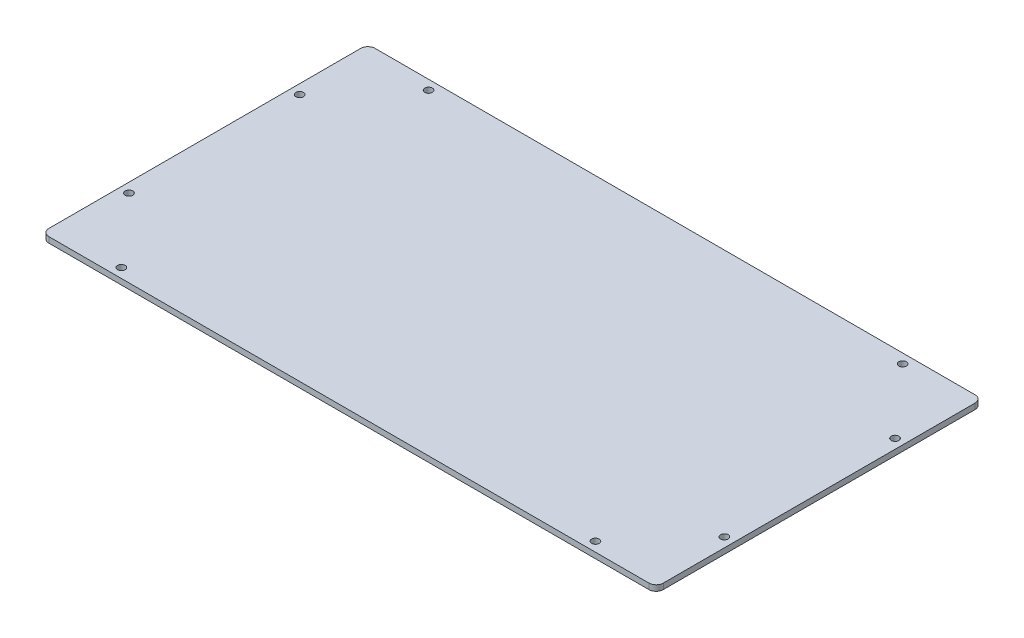
from build123d import *

# Parameters (mm, degrees)
SKETCH_1_R      = 2
EXTRUDE_1_DEPTH = 3


with BuildPart() as part:
    # 草图1 → 凸台-拉伸1 (new body)
    with BuildSketch(Plane.XZ.offset(3)):
        with BuildLine():
            Line((162, -82.2), (162, 82.2))
            ThreePointArc((162, 82.2), (160.887005769, 84.887005769), (158.2, 86))
            Line((158.2, 86), (-158.2, 86))
            ThreePointArc((-158.2, 86), (-160.887005769, 84.887005769), (-162, 82.2))
            Line((-162, 82.2), (-162, -82.2))
            ThreePointArc((-162, -82.2), (-160.887005769, -84.887005769), (-158.2, -86))
            Line((-158.2, -86), (158.2, -86))
            ThreePointArc((158.2, -86), (160.887005769, -84.887005769), (162, -82.2))
        make_face()
        with Locations((157, 45)):
            Circle(SKETCH_1_R, mode=Mode.SUBTRACT)
        with Locations((157, -45)):
            Circle(SKETCH_1_R, mode=Mode.SUBTRACT)
        with Locations((125, -81)):
            Circle(SKETCH_1_R, mode=Mode.SUBTRACT)
        with Locations((-125, -81)):
            Circle(SKETCH_1_R, mode=Mode.SUBTRACT)
        with Locations((-157, -45)):
            Circle(SKETCH_1_R, mode=Mode.SUBTRACT)
        with Locations((-157, 45)):
            Circle(SKETCH_1_R, mode=Mode.SUBTRACT)
        with Locations((125, 81)):
            Circle(SKETCH_1_R, mode=Mode.SUBTRACT)
        with Locations((-125, 81)):
            Circle(SKETCH_1_R, mode=Mode.SUBTRACT)
    extrude(amount=-EXTRUDE_1_DEPTH)


solid = part.part
